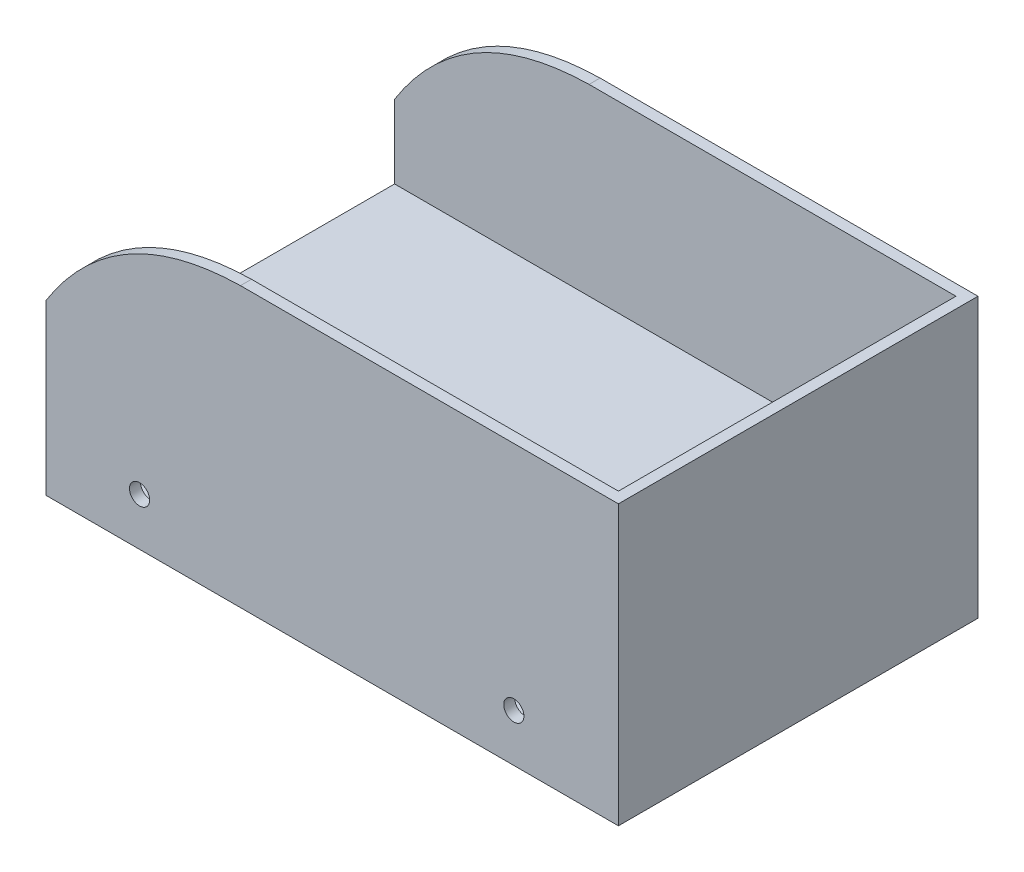
from build123d import *

# Parameters (mm, degrees)
SKETCH1_W           = 1530
SKETCH1_H           = 230
BOSS_EXTRUDE3_DEPTH = 30
SKETCH9_R           = 27.5
CUT_EXTRUDE1_DEPTH  = 31.0000001
SKETCH10_W          = 1530
SKETCH10_H          = 980
BOSS_EXTRUDE4_DEPTH = 30
SKETCH11_W          = 980
SKETCH11_H          = 760
BOSS_EXTRUDE5_DEPTH = 30
SKETCH12_W          = 920
SKETCH12_H          = 30
BOSS_EXTRUDE6_DEPTH = 1530
SKETCH13_W          = 20
SKETCH13_H          = 200
BOSS_EXTRUDE7_DEPTH = 1530
SKETCH14_R          = 27.5
SKETCH14_R_2        = 40
CUT_EXTRUDE3_DEPTH  = 500
BOSS_EXTRUDE8_START = 500
SKETCH17_W          = 110
SKETCH17_H          = 24.94
BOSS_EXTRUDE8_DEPTH = 300


with BuildPart() as part:
    # Sketch1 → Boss-Extrude3 (new body)
    with BuildSketch(Plane.XY):
        with BuildLine():
            Line((765, 500), (-235, 500))
            add(Edge.make_bspline(
                [(-235, 500), (-580.943747407, 493.32484482), (-765, 200)],
                knots=[0, 0, 0, 1, 1, 1], degree=2))
            Line((-765, 200), (-765, 0))
            Line((-765, 0), (765, 0))
            Line((765, 0), (765, 500))
        make_face()
        with Locations((0, -115)):
            Rectangle(SKETCH1_W, SKETCH1_H)
    boss_extrude3 = extrude(amount=BOSS_EXTRUDE3_DEPTH)

    # Sketch9 → Cut-Extrude1 (cut, through all)
    with BuildSketch(Plane.XY.offset(30)):
        with Locations((-510, -130)):
            Circle(SKETCH9_R)
        with Locations((510, -130)):
            Circle(SKETCH9_R)
    cut_extrude1 = extrude(amount=-CUT_EXTRUDE1_DEPTH, mode=Mode.SUBTRACT)

    # Sketch10 → Boss-Extrude4 (add)
    with BuildSketch(Plane.XZ.offset(230)):
        with Locations((0, -460)):
            Rectangle(SKETCH10_W, SKETCH10_H)
    extrude(amount=BOSS_EXTRUDE4_DEPTH)

    # Sketch11 → Boss-Extrude5 (add)
    with BuildSketch(Plane(origin=(765, 0, 0), x_dir=(0, 0, -1), z_dir=(1, 0, 0))):
        with Locations((460, 120)):
            Rectangle(SKETCH11_W, SKETCH11_H)
    boss_extrude5 = extrude(amount=BOSS_EXTRUDE5_DEPTH)

    # Mirror3: Boss-Extrude3, Cut-Extrude1, Boss-Extrude5 across plane
    add(boss_extrude3.mirror(Plane.XY.offset(-460)))
    add(cut_extrude1.mirror(Plane.XY.offset(-460)), mode=Mode.SUBTRACT)
    add(boss_extrude5.mirror(Plane.XY.offset(-460)))

    # Sketch12 → Boss-Extrude6 (add)
    with BuildSketch(Plane.ZY.offset(-765)):
        with Locations((-460, -15)):
            Rectangle(SKETCH12_W, SKETCH12_H)
    extrude(amount=BOSS_EXTRUDE6_DEPTH)

    # Sketch13 → Boss-Extrude7 (add)
    with BuildSketch(Plane.ZY.offset(765)):
        with Locations((-670, -130)):
            Rectangle(SKETCH13_W, SKETCH13_H)
        with Locations((-250, -130)):
            Rectangle(SKETCH13_W, SKETCH13_H)
    extrude(amount=-BOSS_EXTRUDE7_DEPTH)

    # Sketch14 → Cut-Extrude3 (cut)
    with BuildSketch(Plane.XY.offset(-240)):
        with Locations((-510, -130)):
            Circle(SKETCH14_R)
        with Locations((0, -130)):
            Circle(SKETCH14_R_2)
        with Locations((510, -130)):
            Circle(SKETCH14_R)
    extrude(amount=-CUT_EXTRUDE3_DEPTH, mode=Mode.SUBTRACT)

    # Sketch17 → Boss-Extrude8 (add)
    with BuildSketch(Plane.ZY.offset(-765).offset(BOSS_EXTRUDE8_START)):
        with Locations((-460, -217.53)):
            Rectangle(SKETCH17_W, SKETCH17_H)
    extrude(amount=BOSS_EXTRUDE8_DEPTH)


solid = part.part
